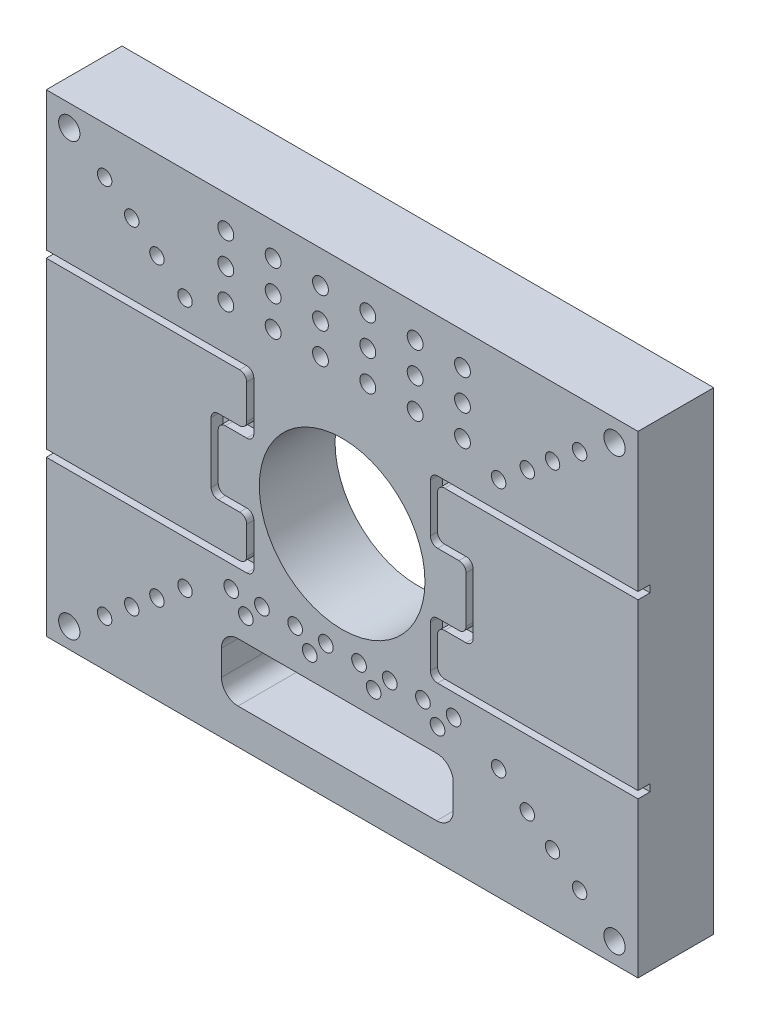
from build123d import *

# Parameters (mm, degrees)
CROQUIS1_W                              = 250
CROQUIS1_H                              = 200
SALIENTE_EXTRUIR1_DEPTH                 = 32
TALADRO_DE_MARGEN_PARA_M1_61_AT_2_COUNT = 2
TALADRO_DE_MARGEN_PARA_M1_61_AT_2_PITCH = 85.006759982
TALADRO_DE_MARGEN_PARA_M1_61_AT_3_COUNT = 2
TALADRO_DE_MARGEN_PARA_M1_61_AT_3_PITCH = 84.670933667
TALADRO_DE_MARGEN_PARA_M1_61_AT_4_COUNT = 2
TALADRO_DE_MARGEN_PARA_M1_61_AT_4_PITCH = 100.198270269
TALADRO_DE_MARGEN_PARA_M1_61_AT_5_COUNT = 2
TALADRO_DE_MARGEN_PARA_M1_61_AT_5_PITCH = 113.839242053
TALADRO_DE_MARGEN_PARA_M1_61_AT_6_COUNT = 2
TALADRO_DE_MARGEN_PARA_M1_61_AT_6_PITCH = 128.488877244
TALADRO_DE_MARGEN_PARA_M1_61_AT_7_COUNT = 2
TALADRO_DE_MARGEN_PARA_M1_61_AT_7_PITCH = 100.198270269
TALADRO_DE_MARGEN_PARA_M1_61_AT_8_COUNT = 2
TALADRO_DE_MARGEN_PARA_M1_61_AT_8_PITCH = 113.839242053
TALADRO_DE_MARGEN_PARA_M1_61_AT_9_COUNT = 2
TALADRO_DE_MARGEN_PARA_M1_61_AT_9_PITCH = 128.488877244
TALADRO1_D                              = 70
TALADRO2_D                              = 6.7
TALADRO2_DEPTH                          = 27.4
MATRIZL1_COUNT                          = 6
MATRIZL1_PITCH                          = 20
MATRIZL1_COUNT_DIR2                     = 3
MATRIZL1_PITCH_DIR2                     = 13
CORTAR_EXTRUIR1_DEPTH                   = 33
TALADRO3_D                              = 9
TALADRO3_DEPTH                          = 32
TALADRO4_D                              = 6.2
TALADRO4_DEPTH                          = 32
MATRIZL2_COUNT                          = 4
MATRIZL2_PITCH                          = 27
CORTAR_EXTRUIR2_DEPTH                   = 5.1


with BuildPart() as part:
    # Croquis1 → Saliente-Extruir1 (new body)
    with BuildSketch(Plane.XY):
        Rectangle(CROQUIS1_W, CROQUIS1_H)
    extrude(amount=SALIENTE_EXTRUIR1_DEPTH)

    # Croquis3 → Taladro de margen para M1.61 (revolve, cut)
    with BuildSketch(Plane(origin=(0, 0, 32), x_dir=(0, -1, 0), z_dir=(1, 0, 0))):
        Polygon((0, 0), (0, 21.832624888), (3.05, 20), (3.05, 0), align=None)
    taladro_de_margen_para_m1_61 = revolve(axis=Axis((0, 0, 38.35), (0, 0, -1)), mode=Mode.SUBTRACT)

    # Taladro de margen para M1.61 at 2: Taladro de margen para M1.61 ×2
    with Locations(*[Vector(-0.780868809, 0.624695048, 0) * (i * TALADRO_DE_MARGEN_PARA_M1_61_AT_2_PITCH) for i in range(1, TALADRO_DE_MARGEN_PARA_M1_61_AT_2_COUNT)]):
        add(taladro_de_margen_para_m1_61, mode=Mode.SUBTRACT)

    # Taladro de margen para M1.61 at 3: Taladro de margen para M1.61 ×2
    with Locations(*[Vector(0.780868809, 0.624695048, 0) * (i * TALADRO_DE_MARGEN_PARA_M1_61_AT_3_PITCH) for i in range(1, TALADRO_DE_MARGEN_PARA_M1_61_AT_3_COUNT)]):
        add(taladro_de_margen_para_m1_61, mode=Mode.SUBTRACT)

    # Taladro de margen para M1.61 at 4: Taladro de margen para M1.61 ×2
    with Locations(*[Vector(-0.780868809, 0.624695048, 0) * (i * TALADRO_DE_MARGEN_PARA_M1_61_AT_4_PITCH) for i in range(1, TALADRO_DE_MARGEN_PARA_M1_61_AT_4_COUNT)]):
        add(taladro_de_margen_para_m1_61, mode=Mode.SUBTRACT)

    # Taladro de margen para M1.61 at 5: Taladro de margen para M1.61 ×2
    with Locations(*[Vector(-0.780868809, 0.624695048, 0) * (i * TALADRO_DE_MARGEN_PARA_M1_61_AT_5_PITCH) for i in range(1, TALADRO_DE_MARGEN_PARA_M1_61_AT_5_COUNT)]):
        add(taladro_de_margen_para_m1_61, mode=Mode.SUBTRACT)

    # Taladro de margen para M1.61 at 6: Taladro de margen para M1.61 ×2
    with Locations(*[Vector(-0.780868809, 0.624695048, 0) * (i * TALADRO_DE_MARGEN_PARA_M1_61_AT_6_PITCH) for i in range(1, TALADRO_DE_MARGEN_PARA_M1_61_AT_6_COUNT)]):
        add(taladro_de_margen_para_m1_61, mode=Mode.SUBTRACT)

    # Taladro de margen para M1.61 at 7: Taladro de margen para M1.61 ×2
    with Locations(*[Vector(0.780868809, 0.624695048, 0) * (i * TALADRO_DE_MARGEN_PARA_M1_61_AT_7_PITCH) for i in range(1, TALADRO_DE_MARGEN_PARA_M1_61_AT_7_COUNT)]):
        add(taladro_de_margen_para_m1_61, mode=Mode.SUBTRACT)

    # Taladro de margen para M1.61 at 8: Taladro de margen para M1.61 ×2
    with Locations(*[Vector(0.780868809, 0.624695048, 0) * (i * TALADRO_DE_MARGEN_PARA_M1_61_AT_8_PITCH) for i in range(1, TALADRO_DE_MARGEN_PARA_M1_61_AT_8_COUNT)]):
        add(taladro_de_margen_para_m1_61, mode=Mode.SUBTRACT)

    # Taladro de margen para M1.61 at 9: Taladro de margen para M1.61 ×2
    with Locations(*[Vector(0.780868809, 0.624695048, 0) * (i * TALADRO_DE_MARGEN_PARA_M1_61_AT_9_PITCH) for i in range(1, TALADRO_DE_MARGEN_PARA_M1_61_AT_9_COUNT)]):
        add(taladro_de_margen_para_m1_61, mode=Mode.SUBTRACT)

    # Taladro1 (through all)
    with Locations(Plane.XY.offset(32)):
        with Locations((0, 0)):
            Hole(TALADRO1_D / 2)

    # Taladro2
    with Locations(Plane.XY.offset(32)):
        with Locations((-49.153329834, 86.267300905)):
            taladro2 = Hole(TALADRO2_D / 2, depth=TALADRO2_DEPTH)

    # MatrizL1: Taladro2 6 × 3
    with Locations(*[(i * MATRIZL1_PITCH, -j * MATRIZL1_PITCH_DIR2, 0) for i in range(MATRIZL1_COUNT) for j in range(MATRIZL1_COUNT_DIR2) if (i, j) != (0, 0)]):
        add(taladro2, mode=Mode.SUBTRACT)

    # Croquis8 → Cortar-Extruir1 (cut, through all)
    with BuildSketch(Plane.XY.offset(32)):
        with BuildLine():
            Line((-43.996896727, -60.322383435), (39.93412377, -60.322383435))
            ThreePointArc((39.93412377, -60.322383435), (44.883871238, -62.372635966), (46.93412377, -67.322383435))
            Line((46.93412377, -67.322383435), (46.93412377, -77.99288439))
            ThreePointArc((46.93412377, -77.99288439), (44.883871238, -82.942631859), (39.93412377, -84.99288439))
            Line((39.93412377, -84.99288439), (-43.996896727, -84.99288439))
            ThreePointArc((-43.996896727, -84.99288439), (-48.946644195, -82.942631859), (-50.996896727, -77.99288439))
            Line((-50.996896727, -77.99288439), (-50.996896727, -67.322383435))
            ThreePointArc((-50.996896727, -67.322383435), (-48.946644195, -62.372635966), (-43.996896727, -60.322383435))
        make_face()
    extrude(amount=-CORTAR_EXTRUIR1_DEPTH, mode=Mode.SUBTRACT)

    # Taladro3
    with Locations(Plane.XY.offset(32)):
        with Locations((-115.27706211, 90.880584552), (115.079568005, 90.880584552), (-115.27706211, -91.497895633), (115.079568005, -91.497895633)):
            Hole(TALADRO3_D / 2, depth=TALADRO3_DEPTH)

    # Taladro4
    with Locations(Plane.XY.offset(32)):
        with Locations((-46.86047853, -43.61554633), (-40.685348875, -50.418655272), (-33.882239934, -43.61554633)):
            taladro4 = Hole(TALADRO4_D / 2, depth=TALADRO4_DEPTH)

    # MatrizL2: Taladro4 ×4
    with Locations(*[(i * MATRIZL2_PITCH, 0, 0) for i in range(1, MATRIZL2_COUNT)]):
        add(taladro4, mode=Mode.SUBTRACT)

    # Croquis16 → Cortar-Extruir2 (cut)
    with BuildSketch(Plane.XY.offset(32)):
        with BuildLine():
            Line((-125, 41.368218066), (-40.306611201, 41.368218066))
            ThreePointArc((-40.306611201, 41.368218066), (-38.185290858, 40.48953841), (-37.306611201, 38.368218066))
            Line((-37.306611201, 38.368218066), (-37.306611201, 17.892558504))
            ThreePointArc((-37.306611201, 17.892558504), (-38.185290858, 15.77123816), (-40.306611201, 14.892558504))
            Line((-40.306611201, 14.892558504), (-49.349599589, 14.892558504))
            ThreePointArc((-49.349599589, 14.892558504), (-51.470919933, 14.013878847), (-52.349599589, 11.892558504))
            Line((-52.349599589, 11.892558504), (-52.349599589, -7.680521755))
            ThreePointArc((-52.349599589, -7.680521755), (-51.470919933, -9.801842099), (-49.349599589, -10.680521755))
            Line((-49.349599589, -10.680521755), (-40.306611201, -10.680521755))
            ThreePointArc((-40.306611201, -10.680521755), (-38.185290858, -11.559201412), (-37.306611201, -13.680521755))
            Line((-37.306611201, -13.680521755), (-37.306611201, -31.448443408))
            ThreePointArc((-37.306611201, -31.448443408), (-38.185290858, -33.569763751), (-40.306611201, -34.448443408))
            Line((-40.306611201, -34.448443408), (-125, -34.448443408))
            Line((-125, -34.448443408), (-125, -31.448443408))
            Line((-125, -31.448443408), (-43.306611201, -31.448443408))
            ThreePointArc((-43.306611201, -31.448443408), (-41.185290858, -30.569763751), (-40.306611201, -28.448443408))
            Line((-40.306611201, -28.448443408), (-40.306611201, -16.680521755))
            ThreePointArc((-40.306611201, -16.680521755), (-41.185290858, -14.559201412), (-43.306611201, -13.680521755))
            Line((-43.306611201, -13.680521755), (-52.349599589, -13.680521755))
            ThreePointArc((-52.349599589, -13.680521755), (-54.470919933, -12.801842099), (-55.349599589, -10.680521755))
            Line((-55.349599589, -10.680521755), (-55.349599589, 14.892558504))
            ThreePointArc((-55.349599589, 14.892558504), (-54.470919933, 17.013878847), (-52.349599589, 17.892558504))
            Line((-52.349599589, 17.892558504), (-43.306611201, 17.892558504))
            ThreePointArc((-43.306611201, 17.892558504), (-41.185290858, 18.77123816), (-40.306611201, 20.892558504))
            Line((-40.306611201, 20.892558504), (-40.306611201, 35.368218066))
            ThreePointArc((-40.306611201, 35.368218066), (-41.185290858, 37.48953841), (-43.306611201, 38.368218066))
            Line((-43.306611201, 38.368218066), (-125, 38.368218066))
            Line((-125, 38.368218066), (-125, 41.368218066))
        make_face()
    cortar_extruir2 = extrude(amount=-CORTAR_EXTRUIR2_DEPTH, mode=Mode.SUBTRACT)

    # Simetría1: Cortar-Extruir2 across plane
    add(cortar_extruir2.mirror(Plane(origin=(0, 0, 0), x_dir=(0, 0, 1), z_dir=(1, 0, 0))), mode=Mode.SUBTRACT)

    # Simetría2: Taladro de margen para M1.61 across plane
    add(taladro_de_margen_para_m1_61.mirror(Plane.ZX), mode=Mode.SUBTRACT)

    # Simetría2 copy 1 sketch → Simetría2 copy 1 (revolve, cut)
    with BuildSketch(Plane(origin=(-66.379127462, -53.103301969, 32), x_dir=(0, 1, 0), z_dir=(1, 0, 0))):
        Polygon((0, 0), (0, -21.832624888), (3.05, -20), (3.05, 0), align=None)
    revolve(axis=Axis((-66.379127462, -53.103301969, 38.35), (0, 0, 1)), mode=Mode.SUBTRACT)

    # Simetría2 copy 2 sketch → Simetría2 copy 2 (revolve, cut)
    with BuildSketch(Plane(origin=(66.116891167, -52.893512933, 32), x_dir=(0, 1, 0), z_dir=(1, 0, 0))):
        Polygon((0, 0), (0, -21.832624888), (3.05, -20), (3.05, 0), align=None)
    revolve(axis=Axis((66.116891167, -52.893512933, 38.35), (0, 0, 1)), mode=Mode.SUBTRACT)

    # Simetría2 copy 3 sketch → Simetría2 copy 3 (revolve, cut)
    with BuildSketch(Plane(origin=(-78.241704013, -62.593363211, 32), x_dir=(0, 1, 0), z_dir=(1, 0, 0))):
        Polygon((0, 0), (0, -21.832624888), (3.05, -20), (3.05, 0), align=None)
    revolve(axis=Axis((-78.241704013, -62.593363211, 38.35), (0, 0, 1)), mode=Mode.SUBTRACT)

    # Simetría2 copy 4 sketch → Simetría2 copy 4 (revolve, cut)
    with BuildSketch(Plane(origin=(-88.89351341, -71.114810728, 32), x_dir=(0, 1, 0), z_dir=(1, 0, 0))):
        Polygon((0, 0), (0, -21.832624888), (3.05, -20), (3.05, 0), align=None)
    revolve(axis=Axis((-88.89351341, -71.114810728, 38.35), (0, 0, 1)), mode=Mode.SUBTRACT)

    # Simetría2 copy 5 sketch → Simetría2 copy 5 (revolve, cut)
    with BuildSketch(Plane(origin=(-100.3329566, -80.26636528, 32), x_dir=(0, 1, 0), z_dir=(1, 0, 0))):
        Polygon((0, 0), (0, -21.832624888), (3.05, -20), (3.05, 0), align=None)
    revolve(axis=Axis((-100.3329566, -80.26636528, 38.35), (0, 0, 1)), mode=Mode.SUBTRACT)

    # Simetría2 copy 6 sketch → Simetría2 copy 6 (revolve, cut)
    with BuildSketch(Plane(origin=(78.241704013, -62.593363211, 32), x_dir=(0, 1, 0), z_dir=(1, 0, 0))):
        Polygon((0, 0), (0, -21.832624888), (3.05, -20), (3.05, 0), align=None)
    revolve(axis=Axis((78.241704013, -62.593363211, 38.35), (0, 0, 1)), mode=Mode.SUBTRACT)

    # Simetría2 copy 7 sketch → Simetría2 copy 7 (revolve, cut)
    with BuildSketch(Plane(origin=(88.89351341, -71.114810728, 32), x_dir=(0, 1, 0), z_dir=(1, 0, 0))):
        Polygon((0, 0), (0, -21.832624888), (3.05, -20), (3.05, 0), align=None)
    revolve(axis=Axis((88.89351341, -71.114810728, 38.35), (0, 0, 1)), mode=Mode.SUBTRACT)

    # Simetría2 copy 8 sketch → Simetría2 copy 8 (revolve, cut)
    with BuildSketch(Plane(origin=(100.3329566, -80.26636528, 32), x_dir=(0, 1, 0), z_dir=(1, 0, 0))):
        Polygon((0, 0), (0, -21.832624888), (3.05, -20), (3.05, 0), align=None)
    revolve(axis=Axis((100.3329566, -80.26636528, 38.35), (0, 0, 1)), mode=Mode.SUBTRACT)


solid = part.part
